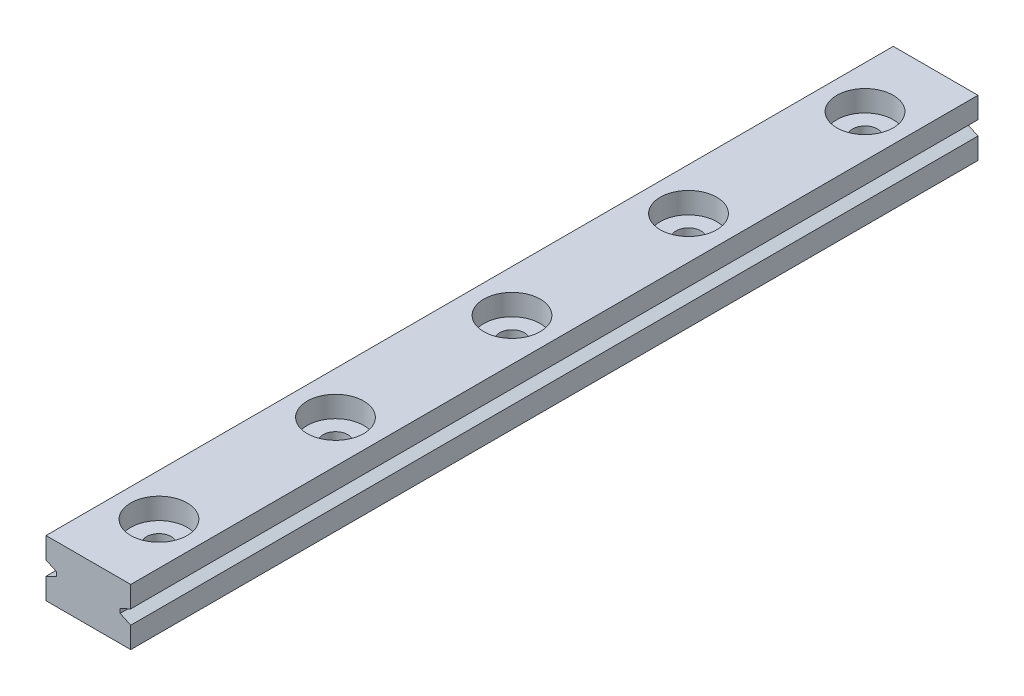
from build123d import *

# Parameters (mm, degrees)
SKETCH_1_W          = 12
SKETCH_1_H          = 8
EXTRUDE_1_DEPTH     = 120
SKETCH_2_R          = 1.75
CUT_EXTRUDE_1_DEPTH = 9
SKETCH_3_R          = 4
CUT_EXTRUDE_2_DEPTH = 3
CUT_EXTRUDE_3_DEPTH = 121


with BuildPart() as part:
    # 草图1 → 凸台-拉伸1 (new body)
    with BuildSketch(Plane.XY):
        Rectangle(SKETCH_1_W, SKETCH_1_H)
    extrude(amount=EXTRUDE_1_DEPTH)

    # 草图2 → 切除-拉伸1 (cut, through all)
    with BuildSketch(Plane(origin=(0, 4, 0), x_dir=(1, 0, 0), z_dir=(0, 1, 0))):
        with Locations((0, -10)):
            Circle(SKETCH_2_R)
        with Locations((0, -35)):
            Circle(SKETCH_2_R)
        with Locations((0, -60)):
            Circle(SKETCH_2_R)
        with Locations((0, -85)):
            Circle(SKETCH_2_R)
        with Locations((0, -110)):
            Circle(SKETCH_2_R)
        with Locations((0, -135)):
            Circle(SKETCH_2_R)
        with Locations((0, -160)):
            Circle(SKETCH_2_R)
        with Locations((0, -185)):
            Circle(SKETCH_2_R)
        with Locations((0, -210)):
            Circle(SKETCH_2_R)
        with Locations((0, -235)):
            Circle(SKETCH_2_R)
        with Locations((0, -260)):
            Circle(SKETCH_2_R)
        with Locations((0, -285)):
            Circle(SKETCH_2_R)
    extrude(amount=-CUT_EXTRUDE_1_DEPTH, mode=Mode.SUBTRACT)

    # 草图3 → 切除-拉伸2 (cut)
    with BuildSketch(Plane(origin=(0, 4, 0), x_dir=(1, 0, 0), z_dir=(0, 1, 0))):
        with Locations((0, -10)):
            Circle(SKETCH_3_R)
        with Locations((0, -35)):
            Circle(SKETCH_3_R)
        with Locations((0, -60)):
            Circle(SKETCH_3_R)
        with Locations((0, -85)):
            Circle(SKETCH_3_R)
        with Locations((0, -110)):
            Circle(SKETCH_3_R)
        with Locations((0, -135)):
            Circle(SKETCH_3_R)
        with Locations((0, -160)):
            Circle(SKETCH_3_R)
        with Locations((0, -185)):
            Circle(SKETCH_3_R)
        with Locations((0, -210)):
            Circle(SKETCH_3_R)
        with Locations((0, -235)):
            Circle(SKETCH_3_R)
        with Locations((0, -260)):
            Circle(SKETCH_3_R)
        with Locations((0, -285)):
            Circle(SKETCH_3_R)
    extrude(amount=-CUT_EXTRUDE_2_DEPTH, mode=Mode.SUBTRACT)

    # 草图4 → 切除-拉伸3 (cut, through all)
    with BuildSketch(Plane(origin=(0, 0, 0), x_dir=(-1, 0, 0), z_dir=(0, 0, -1))):
        Polygon((6, 1), (4.5, 0.3), (4.5, -0.3), (6, -1), align=None)
        Polygon((-6, 1), (-4.5, 0.3), (-4.5, -0.3), (-6, -1), align=None)
    extrude(amount=-CUT_EXTRUDE_3_DEPTH, mode=Mode.SUBTRACT)


solid = part.part
